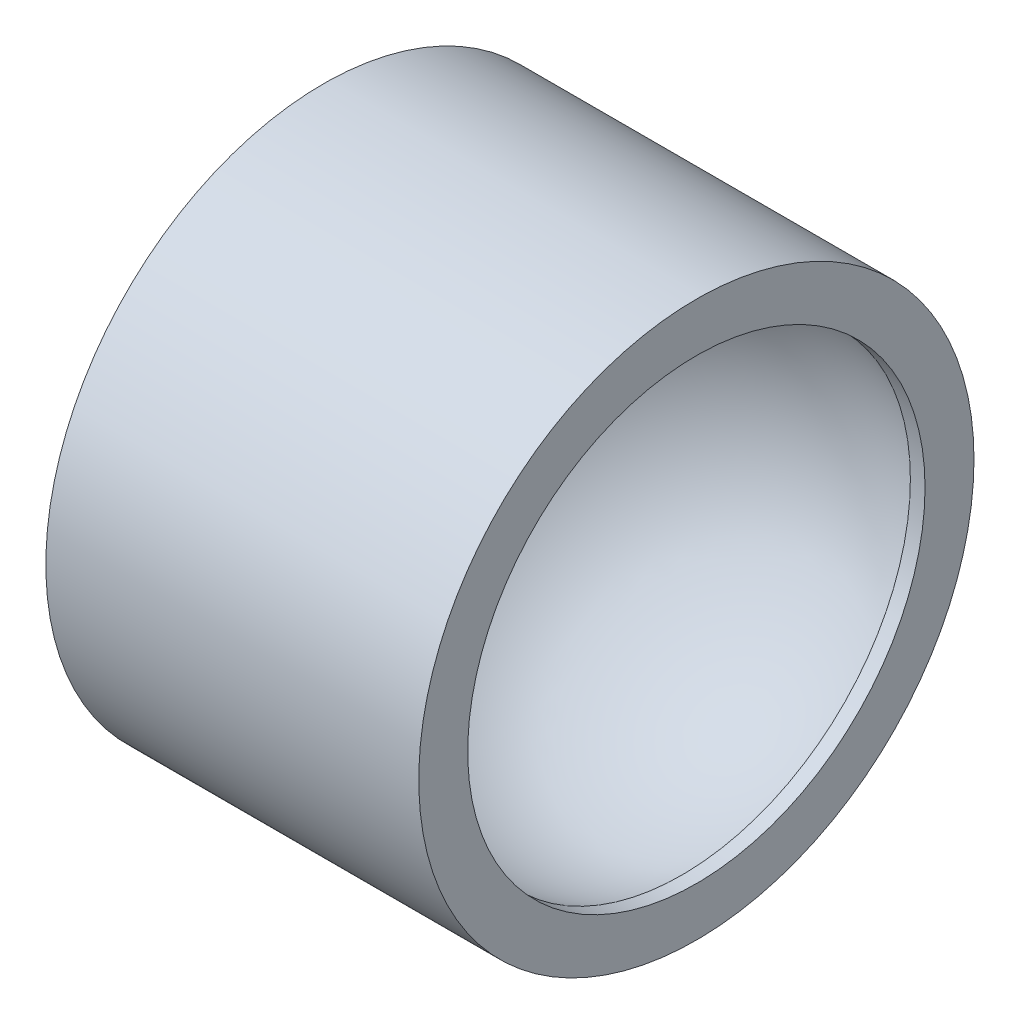
from build123d import *


with BuildPart() as part:
    # Croquis1 → Revolución1 (revolve)
    with BuildSketch(Plane(origin=(0, 0, 0), x_dir=(1, 0, 0), z_dir=(0, 1, 0))):
        with BuildLine():
            Line((-10, 0), (-12.14103606, 0))
            Line((-12.14103606, 0), (-12.14103606, 11.630777084))
            Line((-12.14103606, 11.630777084), (3.482783518, 11.630777084))
            Line((3.482783518, 11.630777084), (3.482783518, 9.579723696))
            Line((3.482783518, 9.579723696), (2.868604871, 9.579723696))
            ThreePointArc((2.868604871, 9.579723696), (-5.971346217, 8.021410372), (-10, 0))
        make_face()
    revolve(axis=Axis((-10, 0, 0), (-1, 0, 0)))


solid = part.part
